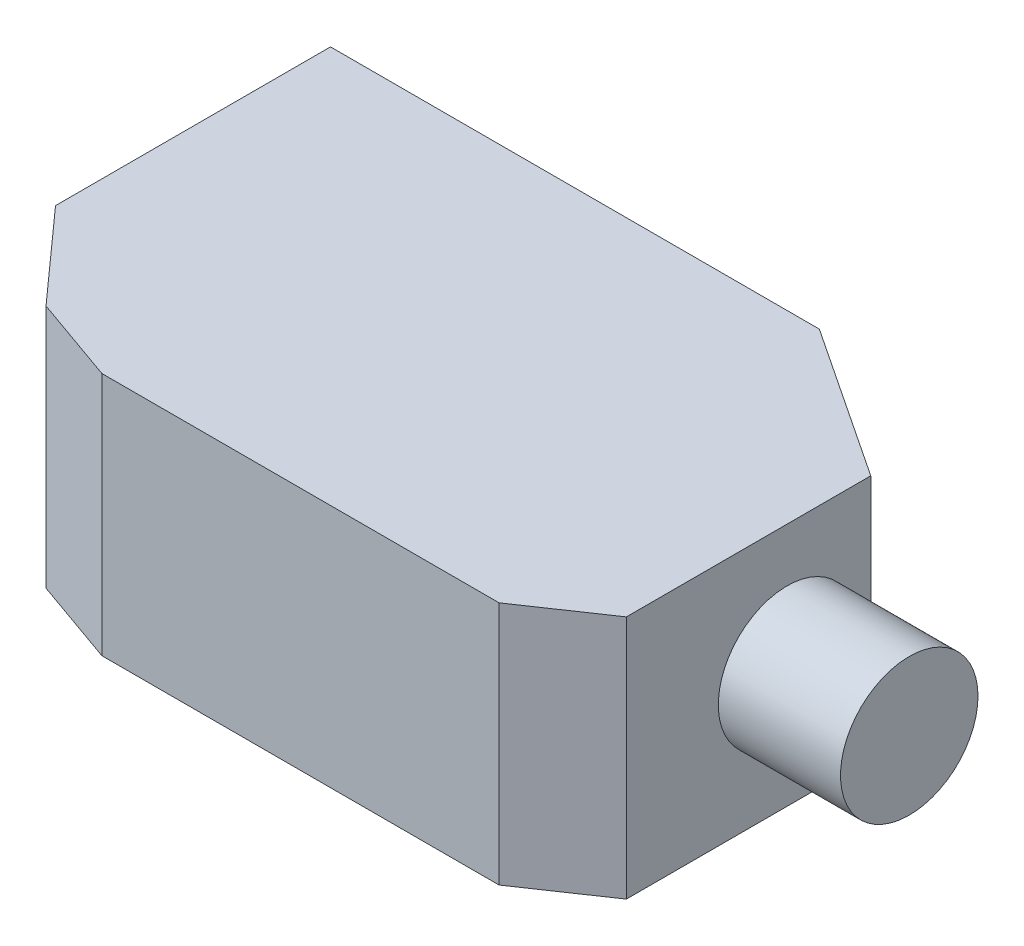
from build123d import *

# Parameters (mm, degrees)
BOSS_EXTRUDE1_DEPTH = 12.7
SKETCH2_R           = 3.571875
BOSS_EXTRUDE2_DEPTH = 6.35


with BuildPart() as part:
    # Sketch1 → Boss-Extrude1 (new body)
    with BuildSketch(Plane(origin=(0, 0, 0), x_dir=(1, 0, 0), z_dir=(0, 1, 0))):
        Polygon((0, 0), (25.4, 0), (33.3375, -5.265141855), (33.3375, -17.965141855), (29.395430976, -20.6375), (8.757930976, -20.6375), (4.267802915, -19.05), (0, -14.2875), align=None)
    extrude(amount=BOSS_EXTRUDE1_DEPTH)

    # Sketch2 → Boss-Extrude2 (add)
    with BuildSketch(Plane(origin=(33.3375, 0, 0), x_dir=(0, 0, -1), z_dir=(1, 0, 0))):
        with Locations((-9.614891855, 6.35)):
            Circle(SKETCH2_R)
    extrude(amount=BOSS_EXTRUDE2_DEPTH)


solid = part.part
